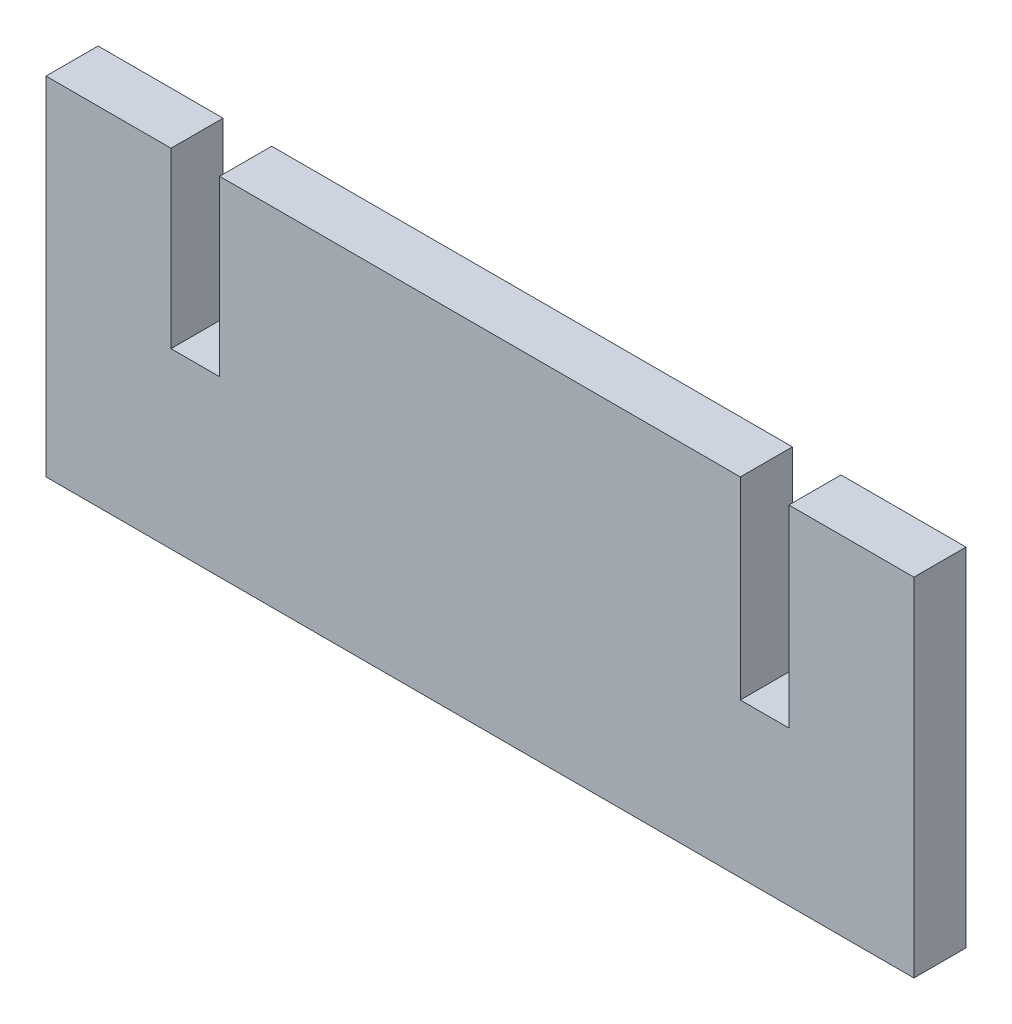
from build123d import *

# Parameters (mm, degrees)
BOSS_EXTRU_1_DEPTH = 3


with BuildPart() as part:
    # Esquisse1 → Boss.-Extru.1 (new body)
    with BuildSketch(Plane.XY):
        Polygon((10, 20), (40, 20), (40, 8.869796004), (42.8, 8.869796004), (42.8, 20), (50, 20), (50, 0), (0, 0), (0, 20), (7.2, 20), (7.2, 10), (10, 10), align=None)
    extrude(amount=BOSS_EXTRU_1_DEPTH)


solid = part.part
